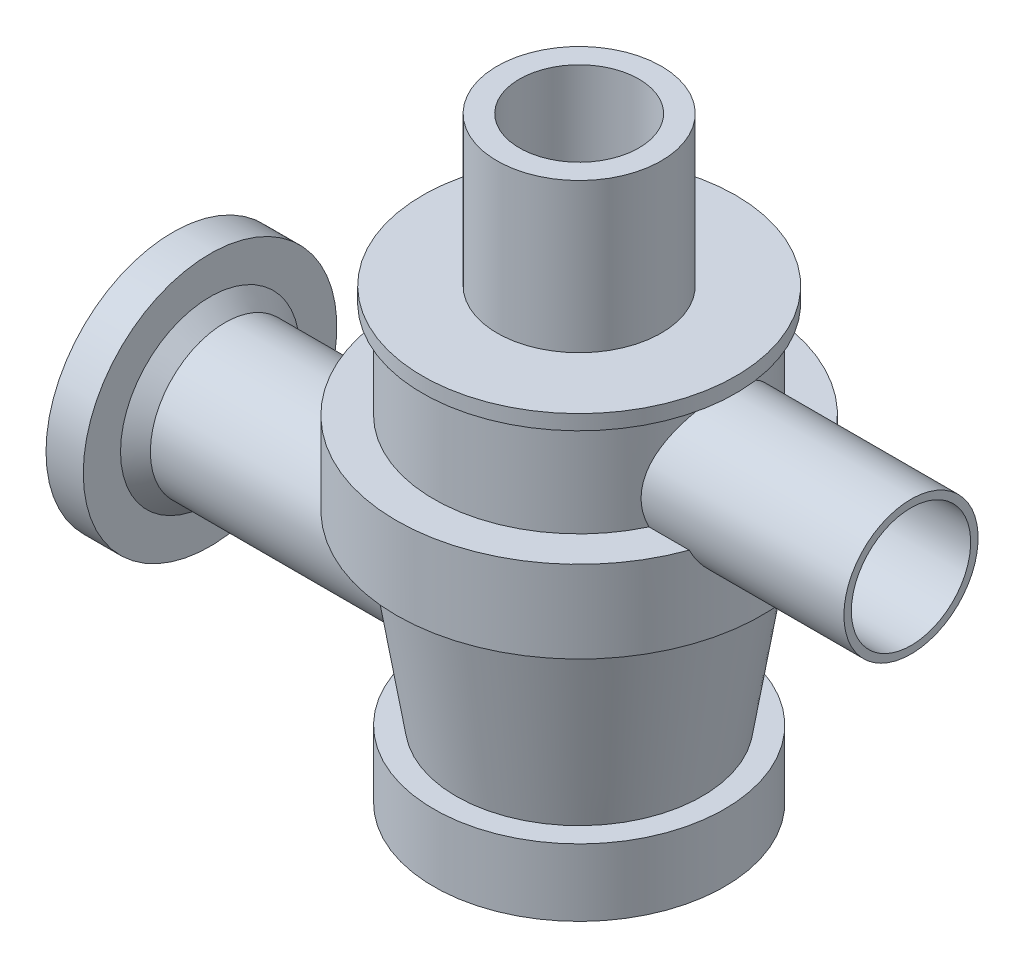
from build123d import *

# Parameters (mm, degrees)
SKETCH4_W                   = 29.001822053
SKETCH4_H                   = 1
M18X2_0_TAPPED_HOLE1_REACH  = 117.623
M18X2_0_TAPPED_HOLE1_BORE_R = 8
F_12_0MM_DOWEL_HOLE1_REACH  = 117.647
F_12_0MM_DOWEL_HOLE1_BORE_R = 6


with BuildPart() as part:
    # Sketch2 → Revolve2 (revolve)
    with BuildSketch(Plane.XY, mode=Mode.PRIVATE) as revolve2_sk:
        Polygon((133.298826334, 67.003789719), (137.796057819, 67.003789719), (137.796057819, 70.003789719), (100.297174174, 70.003789719), (98.297586721, 72.004254538), (98.297586721, 77.000972283), (93.300948764, 77.000972283), (93.300948764, 74.000972283), (95.297586721, 74.000972283), (95.297586721, 70.761999291), (99.054148012, 67.003789719), align=None)
    revolve(revolve2_sk.sketch.rotate(Axis((93.300948764, 60.000024928, 0), (1, 0, 0)), 90), axis=Axis((93.300948764, 60.000024928, 0), (1, 0, 0)))

    # Sketch3 → Revolve3 (revolve)
    with BuildSketch(Plane.XY, mode=Mode.PRIVATE) as revolve3_sk:
        Polygon((164.295977254, 46.995613499), (168.29658455, 71.99063605), (172.287769849, 71.99063605), (172.287769849, 82.995168052), (167.291626788, 82.995168052), (167.291626788, 95.997881631), (168.796118715, 96.030133407), (168.796118715, 98.029686135), (158.800480089, 98.029686135), (158.800480089, 118.027825752), (155.800480089, 118.027825752), (155.800480089, 95.029686135), (164.291626788, 95.029686135), (164.291626788, 79.995168052), (169.287769849, 79.995168052), (169.287769849, 74.99063605), (165.663586472, 74.99063605), (161.171657218, 43.995613499), (164.291626788, 43.995613499), (164.291626788, 40.992834056), (149.287287354, 40.992834056), (149.287287354, 31.991776657), (152.287287354, 31.991776657), (152.287287354, 37.992834056), (167.291626788, 37.992834056), (167.291626788, 46.995613499), align=None)
    revolve(revolve3_sk.sketch.rotate(Axis((147.792001487, 31.991776657, 0), (0, 1, 0)), 90), axis=Axis((147.792001487, 31.991776657, 0), (0, 1, 0)))

    # Sketch4 → Revolve4 (revolve)
    with BuildSketch(Plane.XY, mode=Mode.PRIVATE) as revolve4_sk:
        with Locations((177.786298975, 94.99339539)):
            Rectangle(SKETCH4_W, SKETCH4_H)
    revolve(revolve4_sk.sketch.rotate(Axis((163.285387948, 86.493148721, 0), (1, 0, 0)), 90), axis=Axis((163.285387948, 86.493148721, 0), (1, 0, 0)))

    # M18x2.0 Tapped Hole1 bore (on position points) → M18x2.0 Tapped Hole1 (cut, up to next)
    with BuildSketch(Plane(origin=(192.287210001, 86.493148721, 0), x_dir=(0, 0, 1), z_dir=(1, 0, 0)), mode=Mode.PRIVATE) as m18x2_0_tapped_hole1_sk1:
        Circle(M18X2_0_TAPPED_HOLE1_BORE_R)
    m18x2_0_tapped_hole1_tool1 = extrude(m18x2_0_tapped_hole1_sk1.sketch, amount=-M18X2_0_TAPPED_HOLE1_REACH, mode=Mode.PRIVATE) & part.part
    add(m18x2_0_tapped_hole1_tool1.solids().sort_by_distance((192.28721, 86.493149, 0))[0], mode=Mode.SUBTRACT)

    # Ø12.0mm Dowel Hole1 bore (on position points) → Ø12.0mm Dowel Hole1 (cut, up to next)
    with BuildSketch(Plane(origin=(95.297586721, 60.000024928, 0), x_dir=(0, 0, -1), z_dir=(-1, 0, 0)), mode=Mode.PRIVATE) as f_12_0mm_dowel_hole1_sk1:
        Circle(F_12_0MM_DOWEL_HOLE1_BORE_R)
    f_12_0mm_dowel_hole1_tool1 = extrude(f_12_0mm_dowel_hole1_sk1.sketch, amount=-F_12_0MM_DOWEL_HOLE1_REACH, mode=Mode.PRIVATE) & part.part
    add(f_12_0mm_dowel_hole1_tool1.solids().sort_by_distance((95.297587, 60.000025, 0))[0], mode=Mode.SUBTRACT)


solid = part.part
